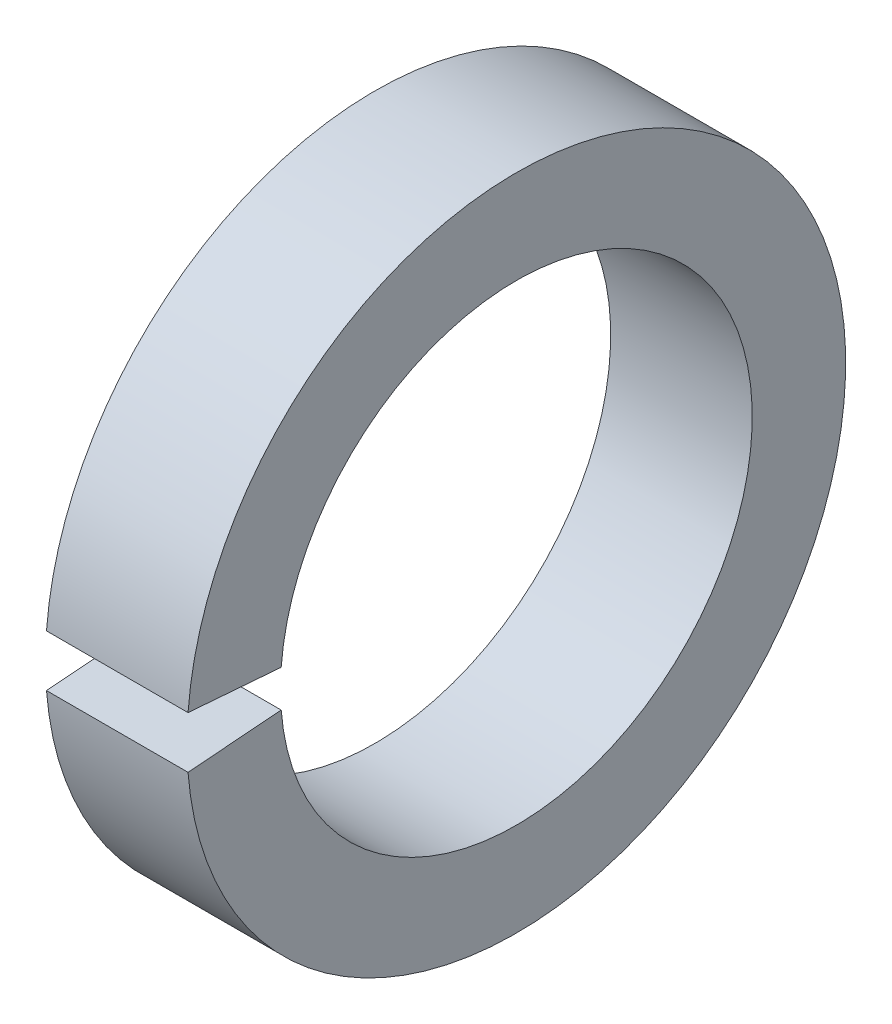
from build123d import *

# Parameters (mm, degrees)
SKETCH1_W = 1.9812
SKETCH1_H = 1.3081
GAP_DEPTH = 2.9812


with BuildPart() as part:
    # Sketch1 → Base-Revolve (revolve)
    with BuildSketch(Plane.XY):
        with Locations((-0.9906, 3.95605)):
            Rectangle(SKETCH1_W, SKETCH1_H)
    revolve(axis=Axis((-34.925, 0, 0), (1, 0, 0)))

    # Sketch2 → Gap (cut, through all)
    with BuildSketch(Plane(origin=(0, 0, 0), x_dir=(0, -1, 0), z_dir=(-1, 0, 0))):
        with BuildLine():
            Line((0, 0), (0.368938363, 4.687806372))
            ThreePointArc((0.368938363, 4.687806372), (0, 4.702302), (-0.368938363, 4.687806372))
            Line((-0.368938363, 4.687806372), (0, 0))
        make_face()
    extrude(amount=GAP_DEPTH, mode=Mode.SUBTRACT)


solid = part.part
